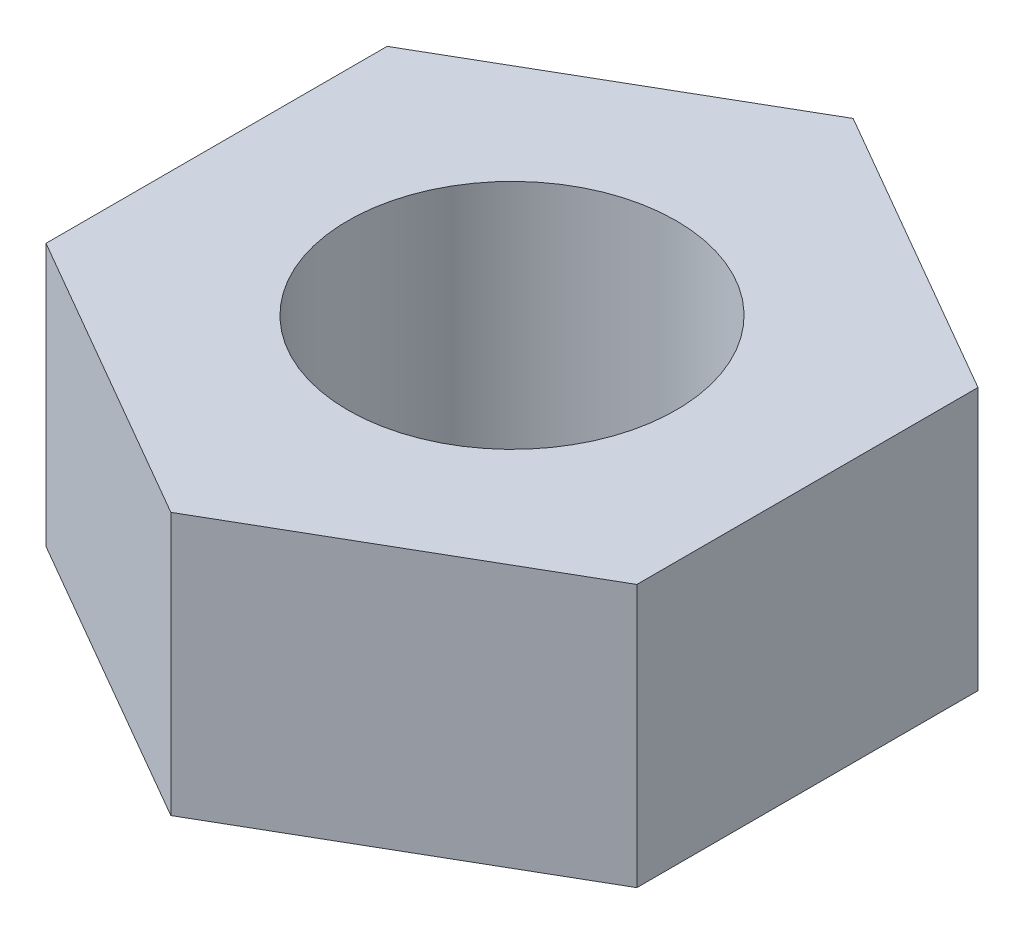
from build123d import *

# Parameters (mm, degrees)
BOSS_EXTRUDE1_DEPTH = 2.4
SKETCH2_R           = 1.5
CUT_EXTRUDE1_DEPTH  = 2.4


with BuildPart() as part:
    # Sketch1 → Boss-Extrude1 (new body)
    with BuildSketch(Plane(origin=(0, 0, 0), x_dir=(1, 0, 0), z_dir=(0, 1, 0))):
        Polygon((0, 3.117691454), (-2.7, 1.558845727), (-2.7, -1.558845727), (0, -3.117691454), (2.7, -1.558845727), (2.7, 1.558845727), align=None)
    extrude(amount=BOSS_EXTRUDE1_DEPTH)

    # Sketch2 → Cut-Extrude1 (cut)
    with BuildSketch(Plane(origin=(0, 2.4, 0), x_dir=(1, 0, 0), z_dir=(0, 1, 0))):
        Circle(SKETCH2_R)
    extrude(amount=-CUT_EXTRUDE1_DEPTH, mode=Mode.SUBTRACT)


solid = part.part
